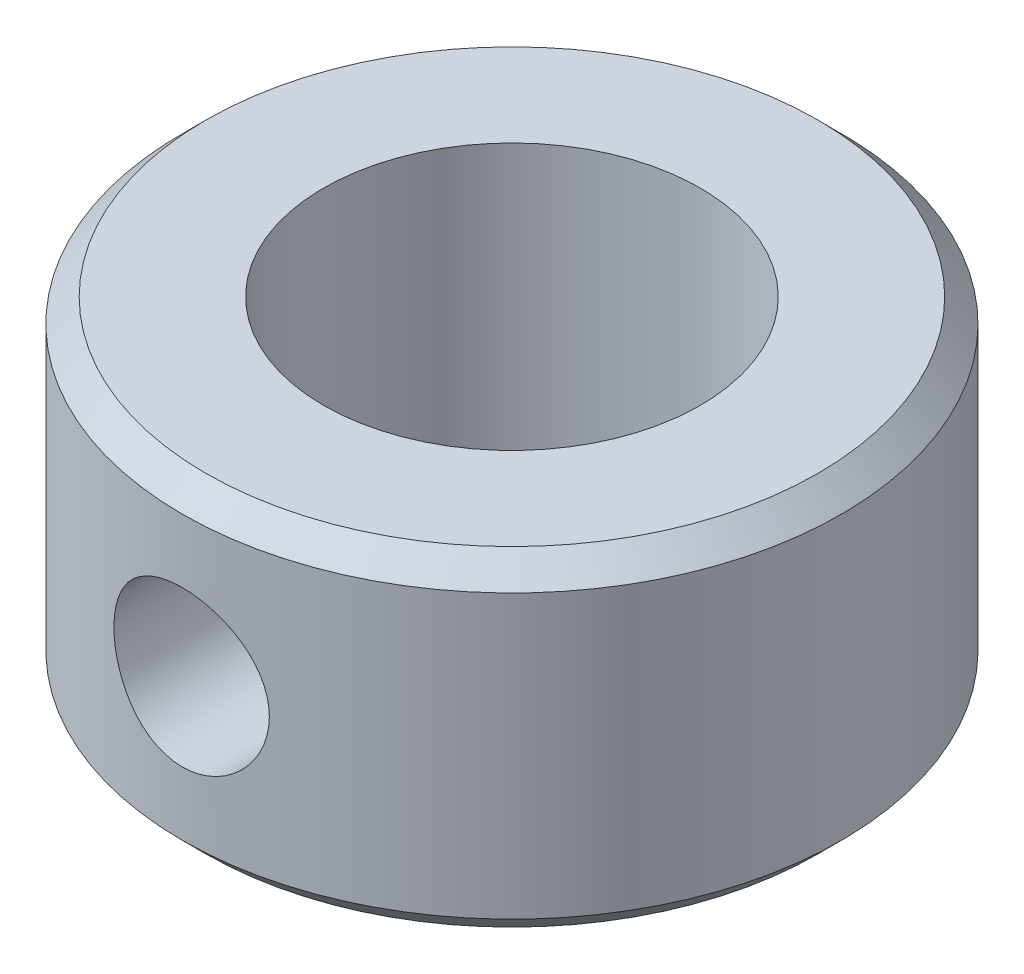
from build123d import *

# Parameters (mm, degrees)
SKETCH1_R                  = 7
SKETCH1_R_2                = 4
BOSS_EXTRUDE1_DEPTH        = 3.5
M4X0_7_TAPPED_HOLE1_REACH  = 18.039
M4X0_7_TAPPED_HOLE1_BORE_R = 1.65
CHAMFER1_SIZE              = 0.5


with BuildPart() as part:
    # Sketch1 → Boss-Extrude1 (new, symmetric)
    with BuildSketch(Plane(origin=(0, 0, 0), x_dir=(1, 0, 0), z_dir=(0, 1, 0))):
        with Locations(Location((0, 0, 0), (0, 0, 270))):
            Circle(SKETCH1_R)
        with Locations(Location((0, 0, 0), (0, 0, 270))):
            Circle(SKETCH1_R_2, mode=Mode.SUBTRACT)
    extrude(amount=BOSS_EXTRUDE1_DEPTH, both=True)

    # M4x0.7 Tapped Hole1 bore → M4x0.7 Tapped Hole1 (cut, up to next)
    with BuildSketch(Plane.XY.offset(7), mode=Mode.PRIVATE) as m4x0_7_tapped_hole1_sk1:
        Circle(M4X0_7_TAPPED_HOLE1_BORE_R)
    m4x0_7_tapped_hole1_tool1 = extrude(m4x0_7_tapped_hole1_sk1.sketch, amount=-M4X0_7_TAPPED_HOLE1_REACH, mode=Mode.PRIVATE) & part.part
    add(m4x0_7_tapped_hole1_tool1.solids().sort_by_distance((0, 0, 7))[0], mode=Mode.SUBTRACT)

    # Chamfer1
    chamfer1_edges = [part.edges().sort_by_distance(p)[0] for p in [
        (0, -3.5, -7),
        (0, 3.5, -7),
    ]]
    chamfer(chamfer1_edges, length=CHAMFER1_SIZE)


solid = part.part
